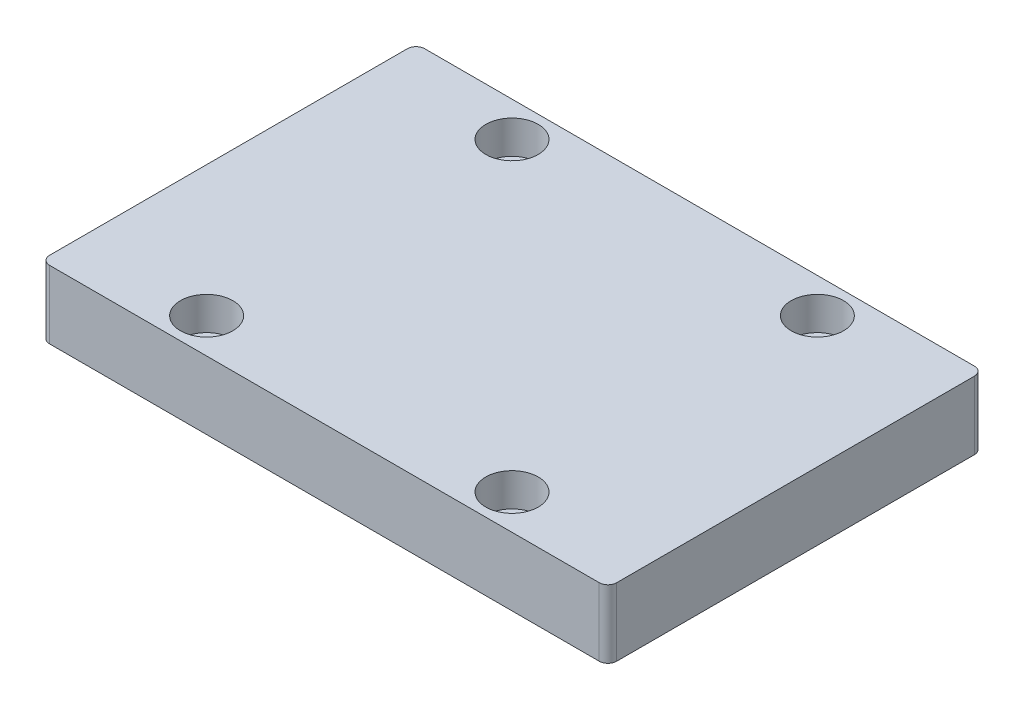
from build123d import *

# Parameters (mm, degrees)
SKETCH2_W           = 65
SKETCH2_H           = 43
BOSS_EXTRUDE1_DEPTH = 7.8
FILLET1_R           = 1
CUT_EXTRUDE1_REACH  = 9.8
SKETCH3_R           = 1.6
SKETCH4_R           = 3
CUT_EXTRUDE2_DEPTH  = 3.8


with BuildPart() as part:
    # Sketch2 → Boss-Extrude1 (new body)
    with BuildSketch(Plane(origin=(0, 0, 0), x_dir=(1, 0, 0), z_dir=(0, 1, 0))):
        Rectangle(SKETCH2_W, SKETCH2_H)
    extrude(amount=BOSS_EXTRUDE1_DEPTH)

    # Fillet1
    fillet1_edges = [part.edges().sort_by_distance(p)[0] for p in [
        (-32.5, 3.9, -21.5),
        (32.5, 3.9, -21.5),
        (32.5, 3.9, 21.5),
        (-32.5, 3.9, 21.5),
    ]]
    fillet(fillet1_edges, radius=FILLET1_R)

    # Sketch3 → Cut-Extrude1 (cut, up to next)
    with BuildSketch(Plane(origin=(0, 7.8, 0), x_dir=(1, 0, 0), z_dir=(0, 1, 0)), mode=Mode.PRIVATE) as cut_extrude1_sk1:
        with Locations((-17.5, 17.5)):
            Circle(SKETCH3_R)
    cut_extrude1_tool1 = extrude(cut_extrude1_sk1.sketch, amount=-CUT_EXTRUDE1_REACH, mode=Mode.PRIVATE) & part.part
    add(cut_extrude1_tool1.solids().sort_by_distance((-17.5, 7.8, -17.5))[0], mode=Mode.SUBTRACT)
    # Sketch3 → Cut-Extrude1 (cut, up to next)
    with BuildSketch(Plane(origin=(0, 7.8, 0), x_dir=(1, 0, 0), z_dir=(0, 1, 0)), mode=Mode.PRIVATE) as cut_extrude1_sk2:
        with Locations((17.5, 17.5)):
            Circle(SKETCH3_R)
    cut_extrude1_tool2 = extrude(cut_extrude1_sk2.sketch, amount=-CUT_EXTRUDE1_REACH, mode=Mode.PRIVATE) & part.part
    add(cut_extrude1_tool2.solids().sort_by_distance((17.5, 7.8, -17.5))[0], mode=Mode.SUBTRACT)
    # Sketch3 → Cut-Extrude1 (cut, up to next)
    with BuildSketch(Plane(origin=(0, 7.8, 0), x_dir=(1, 0, 0), z_dir=(0, 1, 0)), mode=Mode.PRIVATE) as cut_extrude1_sk3:
        with Locations((17.5, -17.5)):
            Circle(SKETCH3_R)
    cut_extrude1_tool3 = extrude(cut_extrude1_sk3.sketch, amount=-CUT_EXTRUDE1_REACH, mode=Mode.PRIVATE) & part.part
    add(cut_extrude1_tool3.solids().sort_by_distance((17.5, 7.8, 17.5))[0], mode=Mode.SUBTRACT)
    # Sketch3 → Cut-Extrude1 (cut, up to next)
    with BuildSketch(Plane(origin=(0, 7.8, 0), x_dir=(1, 0, 0), z_dir=(0, 1, 0)), mode=Mode.PRIVATE) as cut_extrude1_sk4:
        with Locations((-17.5, -17.5)):
            Circle(SKETCH3_R)
    cut_extrude1_tool4 = extrude(cut_extrude1_sk4.sketch, amount=-CUT_EXTRUDE1_REACH, mode=Mode.PRIVATE) & part.part
    add(cut_extrude1_tool4.solids().sort_by_distance((-17.5, 7.8, 17.5))[0], mode=Mode.SUBTRACT)

    # Sketch4 → Cut-Extrude2 (cut)
    with BuildSketch(Plane(origin=(0, 7.8, 0), x_dir=(1, 0, 0), z_dir=(0, 1, 0))):
        with Locations((-17.5, 17.5)):
            Circle(SKETCH4_R)
        with Locations((17.5, 17.5)):
            Circle(SKETCH4_R)
        with Locations((17.5, -17.5)):
            Circle(SKETCH4_R)
        with Locations((-17.5, -17.5)):
            Circle(SKETCH4_R)
    extrude(amount=-CUT_EXTRUDE2_DEPTH, mode=Mode.SUBTRACT)


solid = part.part
